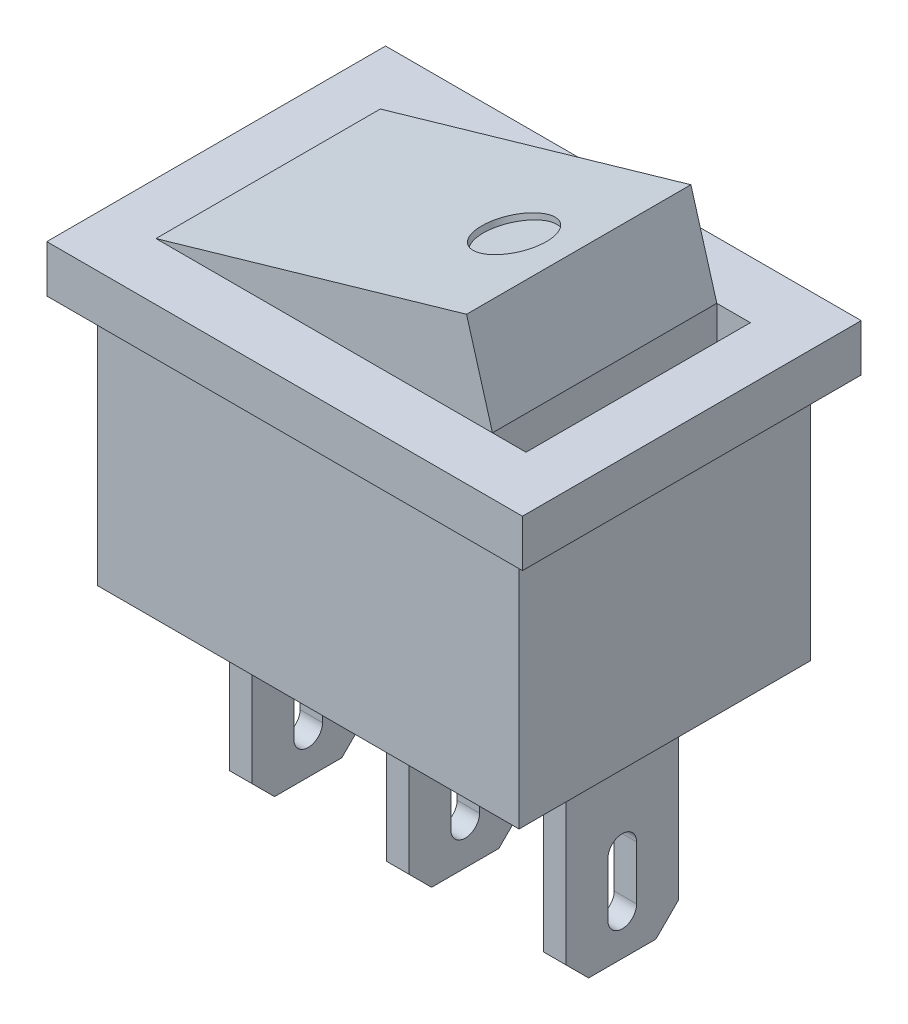
from build123d import *

# Parameters (mm, degrees)
SKETCH1_W                  = 21.2
SKETCH1_H                  = 15.1
BOSS_EXTRUDE1_DEPTH        = 2.1
SKETCH2_W                  = 18.8
SKETCH2_H                  = 13
BOSS_EXTRUDE2_DEPTH        = 11.1
BOSS_EXTRUDE3_DEPTH        = 5
BOSS_EXTRUDE3_DEPTH_BACK   = 5
SKETCH14_W                 = 1.495775322
SKETCH14_H                 = 10
CUT_EXTRUDE1_DEPTH         = 5
SKETCH15_R                 = 1.5
CUT_EXTRUDE2_DEPTH         = 0.25
SKETCH16_W                 = 1
SKETCH16_H                 = 5
BOSS_EXTRUDE4_DEPTH        = 9.2
CUT_EXTRUDE3_DEPTH         = 1
CHAMFER1_SIZE              = 1
LPATTERN1_COUNT            = 2
LPATTERN1_PITCH            = 7
LPATTERN1_COUNT_DIR2       = 2
LPATTERN1_PITCH_DIR2       = 7
CHAMFER1_OF_LPATTERN1_SIZE = 1


with BuildPart() as part:
    # Sketch1 → Boss-Extrude1 (new body)
    with BuildSketch(Plane(origin=(0, 0, 0), x_dir=(1, 0, 0), z_dir=(0, 1, 0))):
        Rectangle(SKETCH1_W, SKETCH1_H)
    extrude(amount=BOSS_EXTRUDE1_DEPTH)

    # Sketch2 → Boss-Extrude2 (add)
    with BuildSketch(Plane.XZ):
        Rectangle(SKETCH2_W, SKETCH2_H)
    extrude(amount=BOSS_EXTRUDE2_DEPTH)

    # Sketch12 → Boss-Extrude3 (add, two sides)
    with BuildSketch(Plane.XY) as boss_extrude3_sk:
        Polygon((-8.285775322, 2.1), (5.558513448, 6.1), (6.714224678, 2.1), align=None)
    extrude(amount=BOSS_EXTRUDE3_DEPTH)
    extrude(boss_extrude3_sk.sketch, amount=-BOSS_EXTRUDE3_DEPTH_BACK)

    # Sketch14 → Cut-Extrude1 (cut)
    with BuildSketch(Plane(origin=(0, 2.1, 0), x_dir=(1, 0, 0), z_dir=(0, 1, 0))):
        with Locations((7.462112339, 0)):
            Rectangle(SKETCH14_W, SKETCH14_H)
    extrude(amount=-CUT_EXTRUDE1_DEPTH, mode=Mode.SUBTRACT)

    # Sketch15 → Cut-Extrude2 (cut)
    with BuildSketch(Plane(origin=(-1.198397572, 4.147740514, 0), x_dir=(0.960704213, 0.277574162, 0), z_dir=(-0.277574162, 0.960704213, 0))):
        with Locations((4.033289675, 0)):
            Circle(SKETCH15_R)
    extrude(amount=-CUT_EXTRUDE2_DEPTH, mode=Mode.SUBTRACT)

    # Sketch16 → Boss-Extrude4 (add)
    with BuildSketch(Plane.XZ.offset(11.1)):
        Rectangle(SKETCH16_W, SKETCH16_H)
    boss_extrude4 = extrude(amount=BOSS_EXTRUDE4_DEPTH)

    # Sketch17 → Cut-Extrude3 (cut)
    with BuildSketch(Plane(origin=(0.5, 0, 0), x_dir=(0, 0, -1), z_dir=(1, 0, 0))):
        with BuildLine():
            Line((-0.639644883, -18.511467052), (-0.639644883, -16.117458369))
            ThreePointArc((-0.639644883, -16.117458369), (0, -15.477813486), (0.639644883, -16.117458369))
            Line((0.639644883, -16.117458369), (0.639644883, -18.511467052))
            ThreePointArc((0.639644883, -18.511467052), (0, -19.151111935), (-0.639644883, -18.511467052))
        make_face()
    cut_extrude3 = extrude(amount=-CUT_EXTRUDE3_DEPTH, mode=Mode.SUBTRACT)

    # Chamfer1
    chamfer1_edges = [part.edges().sort_by_distance(p)[0] for p in [
        (0, -20.3, 2.5),
        (0, -20.3, -2.5),
    ]]
    chamfer(chamfer1_edges, length=CHAMFER1_SIZE)

    # LPattern1: Boss-Extrude4, Cut-Extrude3 2 × 2
    with Locations(*[Vector(1, 0, 0) * (i * LPATTERN1_PITCH) + Vector(-1, 0, 0) * (j * LPATTERN1_PITCH_DIR2) for i in range(LPATTERN1_COUNT) for j in range(LPATTERN1_COUNT_DIR2) if (i, j) != (0, 0)]):
        add(boss_extrude4)
        add(cut_extrude3, mode=Mode.SUBTRACT)

    # Chamfer1 of LPattern1
    chamfer1_of_lpattern1_edges = [part.edges().sort_by_distance(p)[0] for p in [
        (-7, -20.3, 2.5),
        (-7, -20.3, -2.5),
        (7, -20.3, 2.5),
        (7, -20.3, -2.5),
        (0, -20.3, 2.5),
        (0, -20.3, -2.5),
    ]]
    chamfer(chamfer1_of_lpattern1_edges, length=CHAMFER1_OF_LPATTERN1_SIZE)


solid = part.part
